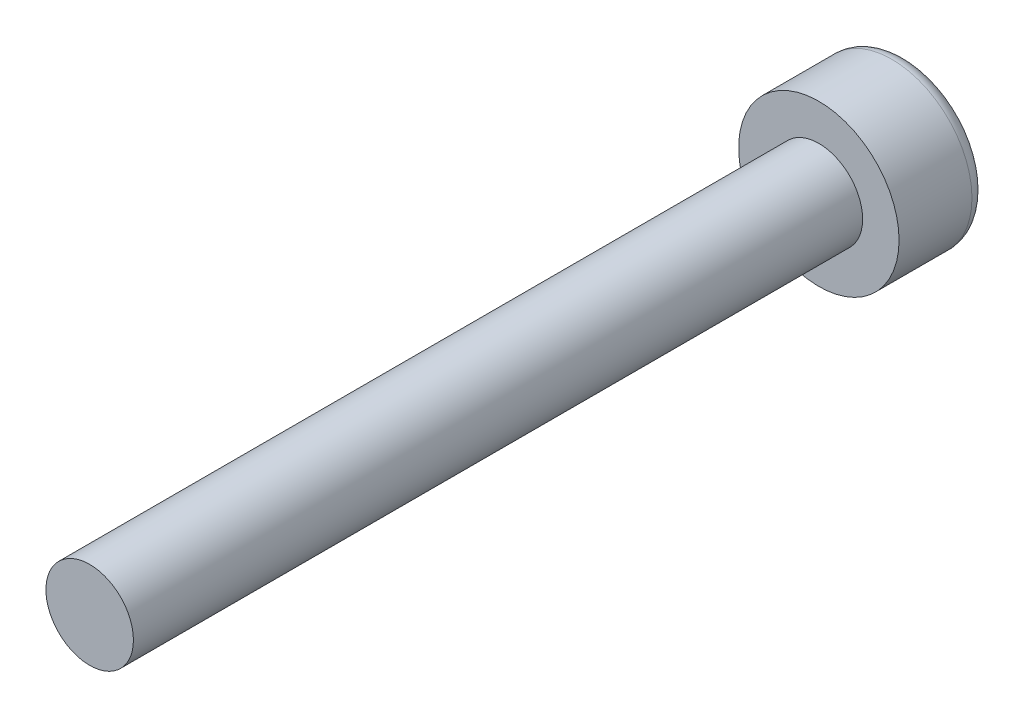
from build123d import *

# Parameters (mm, degrees)
SKETCH_2_R      = 2.75
EXTRUDE_1_DEPTH = 3
SKETCH_3_R      = 1.5
EXTRUDE_2_DEPTH = 25
FILLET_1_R      = 0.5


with BuildPart() as part:
    # ｽｹｯﾁ2 → ﾎﾞｽ - 押し出し1 (new body)
    with BuildSketch(Plane.XY):
        Circle(SKETCH_2_R)
    extrude(amount=EXTRUDE_1_DEPTH)

    # ｽｹｯﾁ3 → ﾎﾞｽ - 押し出し2 (add)
    with BuildSketch(Plane.XY.offset(3)):
        Circle(SKETCH_3_R)
    extrude(amount=EXTRUDE_2_DEPTH)

    # ﾌｨﾚｯﾄ1
    fillet_1_edges = [part.edges().sort_by_distance(p)[0] for p in [
        (-2.75, 0, 0),
    ]]
    fillet(fillet_1_edges, radius=FILLET_1_R)


solid = part.part
